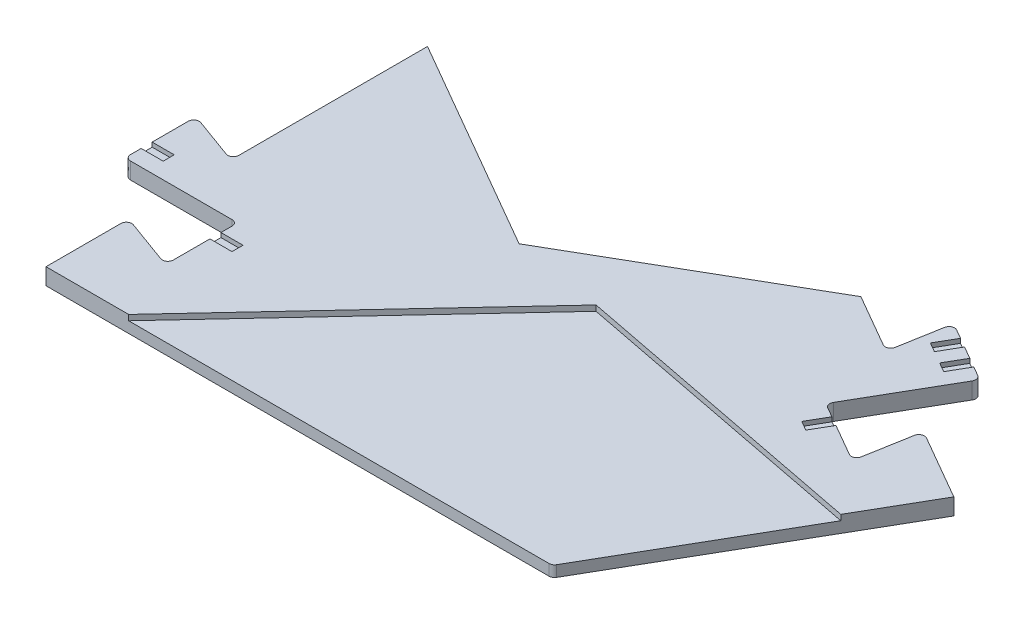
from build123d import *

# Parameters (mm, degrees)
P_IDAT_VYSUNUT_M1_DEPTH  = 3
P_IDAT_VYSUNUT_M2_DEPTH  = 2
ZAOBLIT1_R               = 1
ZAOBLIT2_R               = 1
SKICA2_W                 = 4
SKICA2_H                 = 2
ODEBRAT_VYSUNUT_M1_DEPTH = 0.8


with BuildPart() as part:
    # Skica1 → P_idat vysunut_m1 (new body)
    with BuildSketch(Plane(origin=(0, 0, 0), x_dir=(1, 0, 0), z_dir=(0, 1, 0))):
        Polygon((118.524103266, 46.190077074), (105.53372221, 53.690077074), (103.593400635, 42.685966604), (92.248467845, 49.235966604), (102.473720104, 66.946623035), (91.301992395, 73.396623035), (89.463213481, 62.968389614), (78.635106664, 69.22), (39.317553332, 46.52), (0, 69.22), (0, 33.55662508), (-9.950504516, 37.17831254), (-9.950504516, 24.27831254), (10.5, 24.27831254), (10.5, 11.17831254), (0, 15), (0, 0), (15, 0), (55.910618513, 43.889876884), (111.018549767, 33.190077074), align=None)
    extrude(amount=P_IDAT_VYSUNUT_M1_DEPTH)

    # Skica1_3 → P_idat vysunut_m2 (add)
    with BuildSketch(Plane(origin=(0, 0, 0), x_dir=(1, 0, 0), z_dir=(0, 1, 0))):
        Polygon((91.856249834, 0), (111.018549767, 33.190077074), (55.910618513, 43.889876884), (15, 0), align=None)
    extrude(amount=P_IDAT_VYSUNUT_M2_DEPTH)

    # Zaoblit1
    zaoblit1_edges = [part.edges().sort_by_distance(p)[0] for p in [
        (0, 1.5, -33.55662508),
        (-9.950504516, 1.5, -37.17831254),
        (10.5, 1.5, -24.27831254),
        (-9.950504516, 1.5, -24.27831254),
        (10.5, 1.5, -11.17831254),
        (0, 1.5, -15),
        (105.53372221, 1.5, -53.690077074),
        (103.593400635, 1.5, -42.685966604),
        (92.248467845, 1.5, -49.235966604),
        (89.463213481, 1.5, -62.968389614),
        (91.301992395, 1.5, -73.396623035),
        (102.473720104, 1.5, -66.946623035),
    ]]
    fillet(zaoblit1_edges, radius=ZAOBLIT1_R)

    # Zaoblit2
    zaoblit2_edges = [part.edges().sort_by_distance(p)[0] for p in [
        (91.856249834, 1, 0),
    ]]
    fillet(zaoblit2_edges, radius=ZAOBLIT2_R)

    # Skica2 → Odebrat vysunut_m1 (cut)
    with BuildSketch(Plane(origin=(0, 3, 0), x_dir=(1, 0, 0), z_dir=(0, 1, 0))):
        with Locations((-7.950504516, 28.214238537)):
            Rectangle(SKICA2_W, SKICA2_H)
        with Locations((12.5, 20.242386544)):
            Rectangle(SKICA2_W, SKICA2_H)
        Polygon((94.215365942, 71.714586034), (92.215365942, 68.250484418), (93.947416749, 67.250484418), (95.947416749, 70.714586034), align=None)
        Polygon((96.199082799, 65.950484418), (98.199082799, 69.414586034), (99.931133607, 68.414586034), (97.931133607, 64.950484418), align=None)
        Polygon((96.60970769, 46.718003606), (94.60970769, 43.253901991), (92.877656883, 44.253901991), (94.877656883, 47.718003606), align=None)
    extrude(amount=-ODEBRAT_VYSUNUT_M1_DEPTH, mode=Mode.SUBTRACT)


solid = part.part
